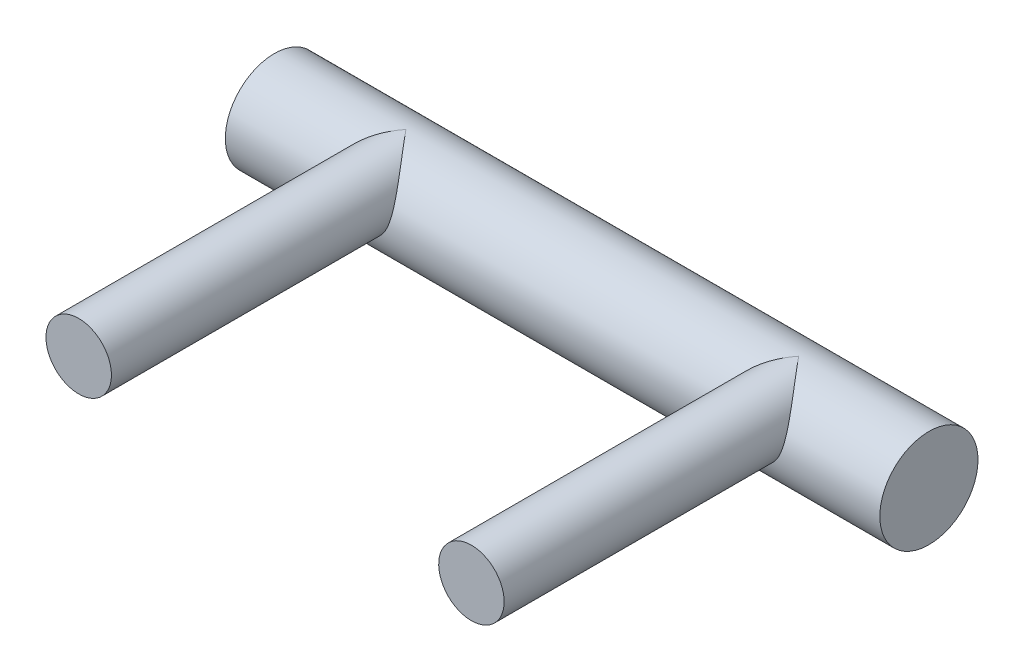
from build123d import *

# Parameters (mm, degrees)
SKETCH3_R           = 9.525
BOSS_EXTRUDE1_DEPTH = 63.5
SKETCH4_R           = 6.35
BOSS_EXTRUDE2_DEPTH = 63.5


with BuildPart() as part:
    # Sketch3 → Boss-Extrude1 (new body, symmetric)
    with BuildSketch(Plane(origin=(0, 0, 0), x_dir=(0, 0, -1), z_dir=(1, 0, 0))):
        Circle(SKETCH3_R)
    extrude(amount=BOSS_EXTRUDE1_DEPTH, both=True)

    # Sketch4 → Boss-Extrude2 (add)
    with BuildSketch(Plane.XY):
        with Locations((-37.967477859, 3.175)):
            Circle(SKETCH4_R)
        with Locations((38.232522141, 3.175)):
            Circle(SKETCH4_R)
    extrude(amount=BOSS_EXTRUDE2_DEPTH)


solid = part.part
